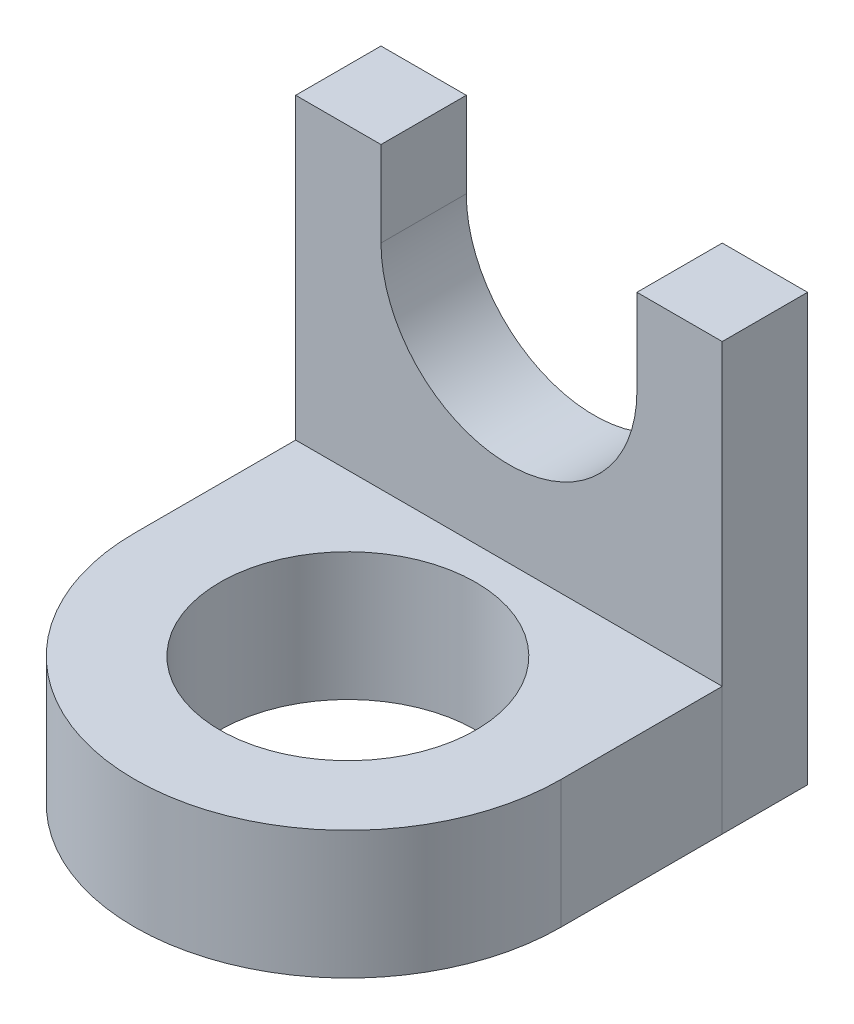
from build123d import *

# Parameters (mm, degrees)
BOSS_EXTRUDE1_DEPTH = 2
SKETCH2_R           = 3
BOSS_EXTRUDE2_DEPTH = 3


with BuildPart() as part:
    # Sketch1 → Boss-Extrude1 (new body)
    with BuildSketch(Plane.XY):
        with BuildLine():
            Line((-5, -5), (5, -5))
            Line((5, -5), (5, 5))
            Line((5, 5), (3, 5))
            Line((3, 5), (3, 3))
            ThreePointArc((3, 3), (0, 0), (-3, 3))
            Line((-3, 3), (-3, 5))
            Line((-3, 5), (-5, 5))
            Line((-5, 5), (-5, -5))
        make_face()
    extrude(amount=BOSS_EXTRUDE1_DEPTH)


with BuildPart() as body_2:
    # Sketch2 → Boss-Extrude2 (new body)
    with BuildSketch(Plane.XZ.offset(5)):
        with BuildLine():
            Line((-5, 2), (5, 2))
            Line((5, 2), (5, 5.776505143))
            ThreePointArc((5, 5.776505143), (0, 10.776505143), (-5, 5.776505143))
            Line((-5, 5.776505143), (-5, 2))
        make_face()
        with Locations((0, 5.776505143)):
            Circle(SKETCH2_R, mode=Mode.SUBTRACT)
    extrude(amount=-BOSS_EXTRUDE2_DEPTH)


solid = Compound([part.part, body_2.part])
